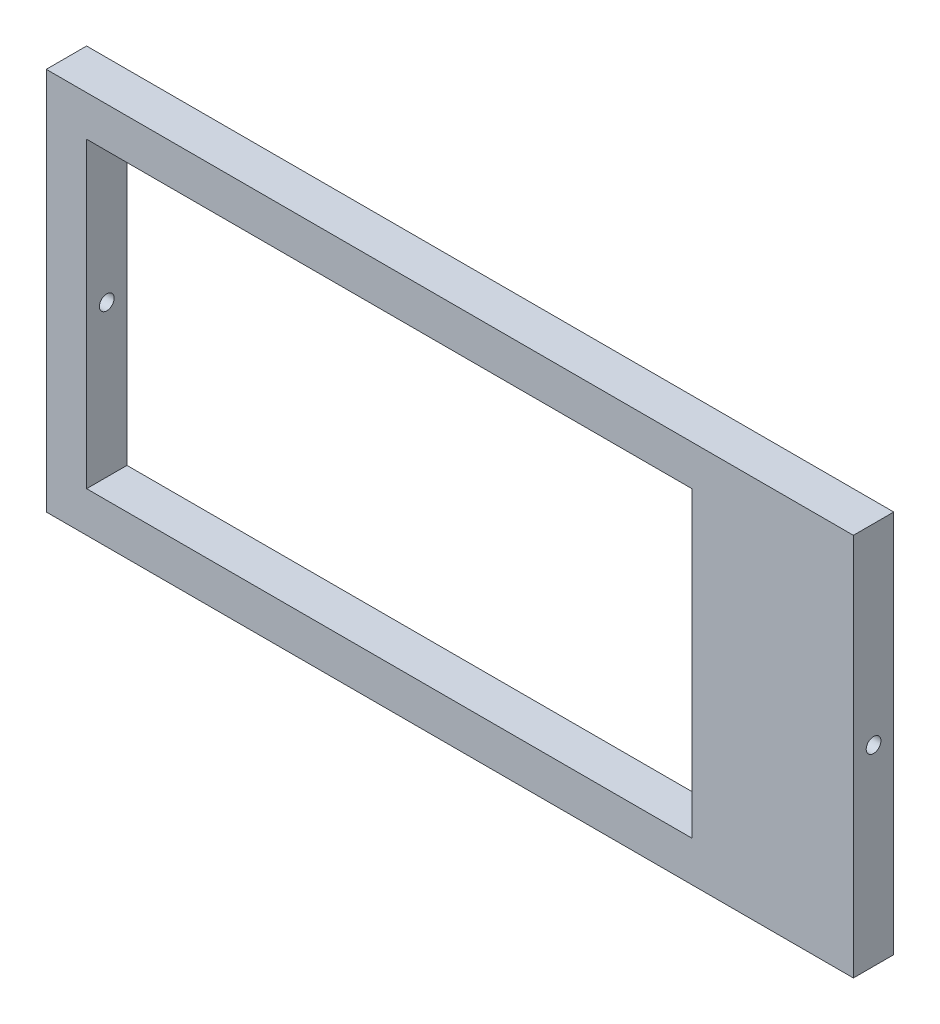
from build123d import *

# Parameters (mm, degrees)
SKETCH1_W           = 40
SKETCH1_H           = 19
SKETCH1_W_2         = 30
SKETCH1_H_2         = 15
BOSS_EXTRUDE1_DEPTH = 2
SKETCH2_R           = 0.365
CUT_EXTRUDE1_DEPTH  = 41


with BuildPart() as part:
    # Sketch1 → Boss-Extrude1 (new body)
    with BuildSketch(Plane.XY):
        with Locations((20, 9.5)):
            Rectangle(SKETCH1_W, SKETCH1_H)
        with Locations((17, 9.5)):
            Rectangle(SKETCH1_W_2, SKETCH1_H_2, mode=Mode.SUBTRACT)
    extrude(amount=BOSS_EXTRUDE1_DEPTH)

    # Sketch2 → Cut-Extrude1 (cut, through all)
    with BuildSketch(Plane(origin=(40, 0, 0), x_dir=(0, 0, -1), z_dir=(1, 0, 0))):
        with Locations((-1, 9.5)):
            Circle(SKETCH2_R)
    extrude(amount=-CUT_EXTRUDE1_DEPTH, mode=Mode.SUBTRACT)


solid = part.part
